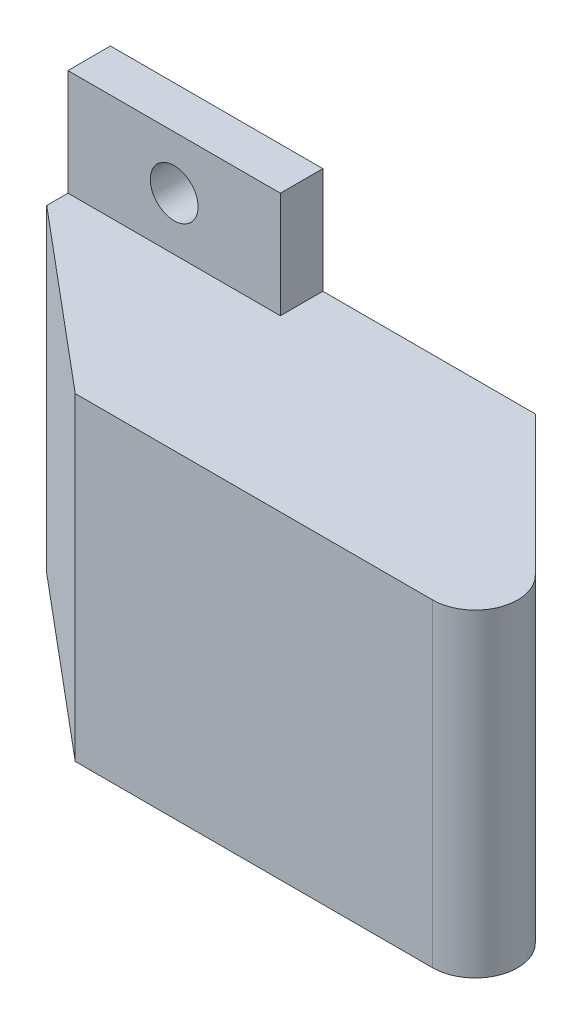
from build123d import *

# Parameters (mm, degrees)
SKETCH1_W           = 20
SKETCH1_H           = 30
BOSS_EXTRUDE1_DEPTH = 60
SKETCH2_W           = 20
SKETCH2_H           = 50
SKETCH2_R           = 2.25
BOSS_EXTRUDE2_DEPTH = 4
CUT_EXTRUDE1_DEPTH  = 41
FILLET1_R           = 4
SKETCH4_W           = 10
SKETCH4_H           = 20
CUT_EXTRUDE2_DEPTH  = 5
CHAMFER1_SIZE       = 14
CHAMFER1_SIZE2      = 16.684550296


with BuildPart() as part:
    # Sketch1 → Boss-Extrude1 (new body)
    with BuildSketch(Plane(origin=(0, 0, 0), x_dir=(0, 0, -1), z_dir=(1, 0, 0))):
        with Locations((10, 15)):
            Rectangle(SKETCH1_W, SKETCH1_H)
    extrude(amount=BOSS_EXTRUDE1_DEPTH)

    # Sketch2 → Boss-Extrude2 (add)
    with BuildSketch(Plane(origin=(0, 0, -20), x_dir=(-1, 0, 0), z_dir=(0, 0, -1))):
        with Locations((-10, 15)):
            Rectangle(SKETCH2_W, SKETCH2_H)
        with Locations((-10, 35)):
            Circle(SKETCH2_R, mode=Mode.SUBTRACT)
        with Locations((-10, -5)):
            Circle(SKETCH2_R, mode=Mode.SUBTRACT)
    extrude(amount=-BOSS_EXTRUDE2_DEPTH)

    # Sketch3 → Cut-Extrude1 (cut, through all)
    with BuildSketch(Plane(origin=(0, 30, 0), x_dir=(1, 0, 0), z_dir=(0, 1, 0))):
        Polygon((60, 20), (40, 20), (60, 0), align=None)
    extrude(amount=-CUT_EXTRUDE1_DEPTH, mode=Mode.SUBTRACT)

    # Fillet1
    fillet1_edges = [part.edges().sort_by_distance(p)[0] for p in [
        (60, 15, 0),
    ]]
    fillet(fillet1_edges, radius=FILLET1_R)

    # Sketch4 → Cut-Extrude2 (cut)
    with BuildSketch(Plane(origin=(30, 0, -30), x_dir=(-0.707106781, 0, -0.707106781), z_dir=(0.707106781, 0, -0.707106781))):
        with Locations((-26.142135624, 15)):
            Rectangle(SKETCH4_W, SKETCH4_H)
    extrude(amount=-CUT_EXTRUDE2_DEPTH, mode=Mode.SUBTRACT)

    # Chamfer1
    chamfer1_edges = [part.edges().sort_by_distance(p)[0] for p in [
        (0, 15, 0),
    ]]
    chamfer1_side = [part.faces().sort_by_distance(p)[0] for p in [
        (0, 15, -10.941176471),
    ]]
    chamfer(chamfer1_edges, length=CHAMFER1_SIZE, length2=CHAMFER1_SIZE2, reference=chamfer1_side[0])


solid = part.part
